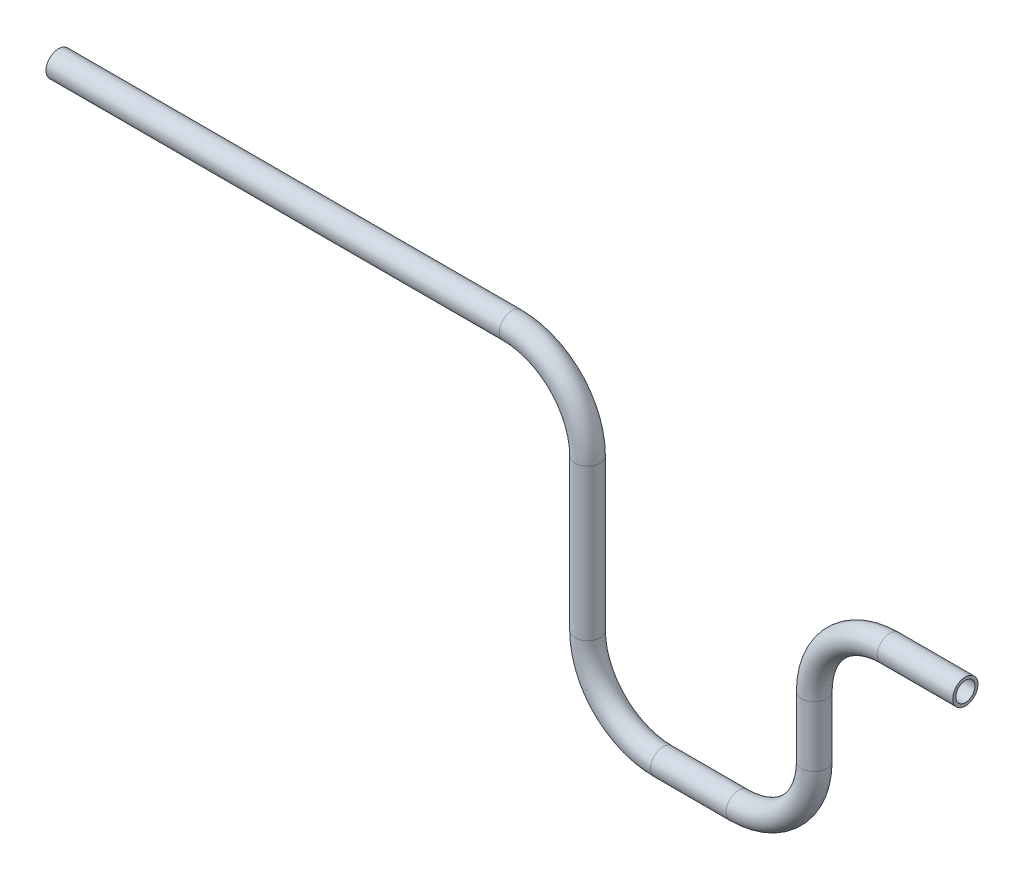
from build123d import *

# Parameters (mm, degrees)
CROQUIS2_R = 8.35
VACIADO1_T = -2


with BuildPart() as part:
    # Barrer1: sweep along a path in Croquis1
    with BuildLine(Plane.XY) as barrer1_path:
        Line((0, 0), (300, 0))
        ThreePointArc((300, 0), (335.355339059, -14.644660941), (350, -50))
        Line((350, -50), (350, -150))
        ThreePointArc((350, -150), (364.644660941, -185.355339059), (400, -200))
        Line((400, -200), (450, -200))
        ThreePointArc((450, -200), (485.355339059, -185.355339059), (500, -150))
        Line((500, -150), (500, -110))
        ThreePointArc((500, -110), (514.644660941, -74.644660941), (550, -60))
        Line((550, -60), (600, -60))
    # Croquis2 → Barrer1 (sweep)
    with BuildSketch(Plane(origin=(0, 0, 0), x_dir=(0, 0, -1), z_dir=(1, 0, 0))):
        Circle(CROQUIS2_R)
    sweep(path=barrer1_path.line)

    # Vaciado1
    vaciado1_openings = [part.faces().sort_by_distance(p)[0] for p in [
        (600, -60, 0),
        (0, 0, 0),
    ]]
    offset(amount=VACIADO1_T, openings=vaciado1_openings, kind=Kind.INTERSECTION)


solid = part.part
